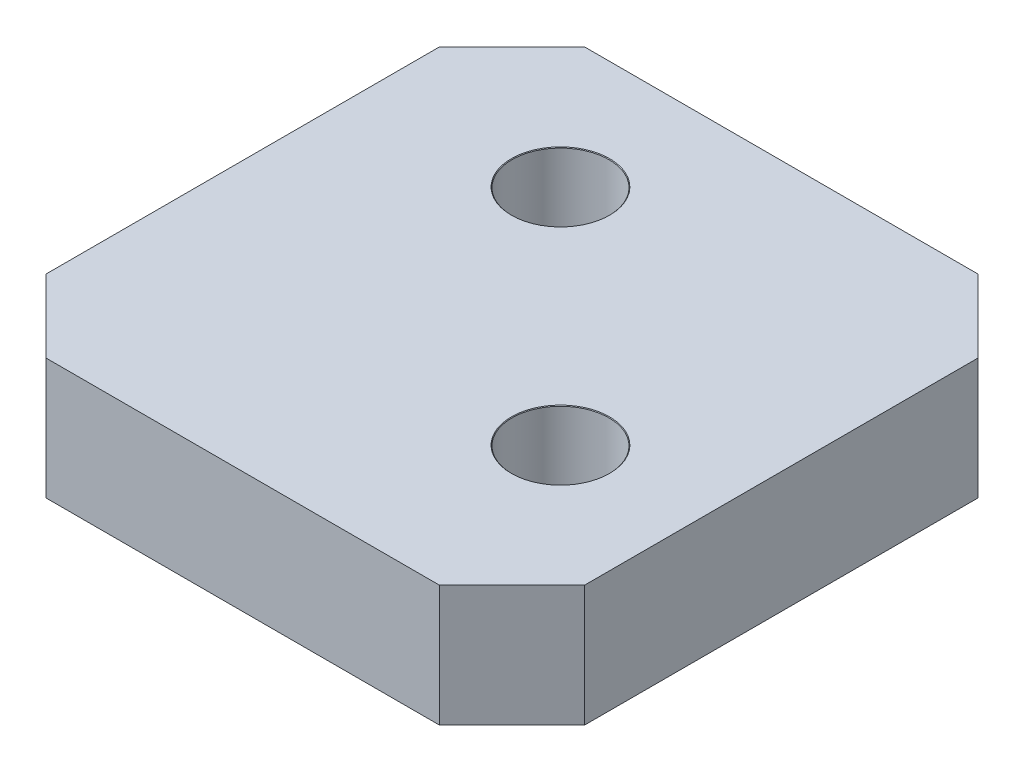
from build123d import *

# Parameters (mm, degrees)
SKETCH1_W                       = 22.225
SKETCH1_H                       = 22.225
BOSS_EXTRUDE1_DEPTH             = 5
F_4_0MM_DOWEL_HOLE3_D           = 4
F_4_0MM_DOWEL_HOLE3_CSINK_D     = 4.05
F_4_0MM_DOWEL_HOLE3_CSINK_ANGLE = 90
CHAMFER1_SIZE                   = 3


with BuildPart() as part:
    # Sketch1 → Boss-Extrude1 (new body)
    with BuildSketch(Plane(origin=(0, 0, 0), x_dir=(1, 0, 0), z_dir=(0, 1, 0))):
        with Locations((11.1125, 11.1125)):
            Rectangle(SKETCH1_W, SKETCH1_H)
    extrude(amount=BOSS_EXTRUDE1_DEPTH)

    # Ø4.0mm Dowel Hole3 (through all)
    with Locations(Plane(origin=(0, 5, 0), x_dir=(1, 0, 0), z_dir=(0, 1, 0))):
        with Locations((7.5, 16.725), (16.725, 7.5)):
            CounterSinkHole(F_4_0MM_DOWEL_HOLE3_D / 2, F_4_0MM_DOWEL_HOLE3_CSINK_D / 2, counter_sink_angle=F_4_0MM_DOWEL_HOLE3_CSINK_ANGLE)

    # Chamfer1
    chamfer1_edges = [part.edges().sort_by_distance(p)[0] for p in [
        (0, 2.5, -22.225),
        (22.225, 2.5, -22.225),
        (22.225, 2.5, 0),
        (0, 2.5, 0),
    ]]
    chamfer(chamfer1_edges, length=CHAMFER1_SIZE)


solid = part.part
